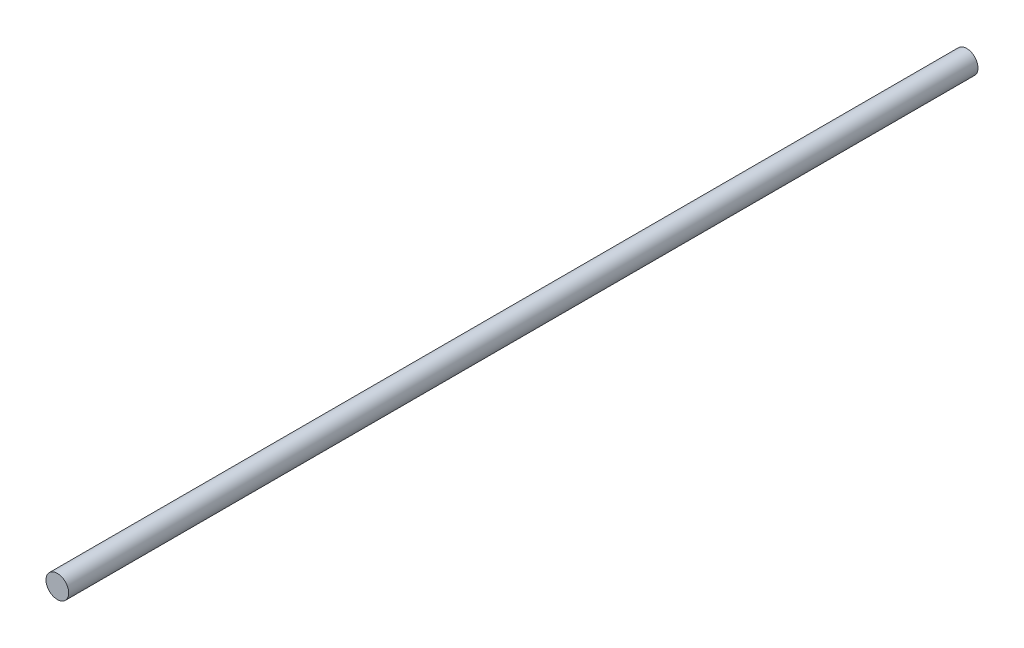
from build123d import *

# Parameters (mm, degrees)
SKETCH1_R      = 0.875
EXTRUDE1_DEPTH = 70


with BuildPart() as part:
    # Sketch1 → Extrude1 (new body)
    with BuildSketch(Plane.XY):
        Circle(SKETCH1_R)
    extrude(amount=EXTRUDE1_DEPTH)


solid = part.part
